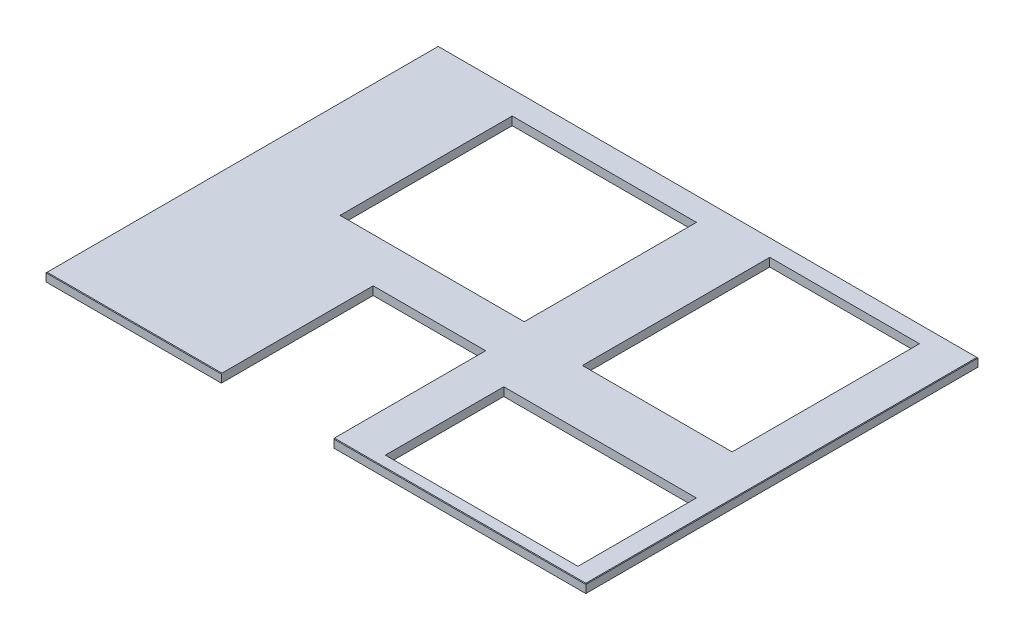
from build123d import *

# Parameters (mm, degrees)
SKETCH1_W           = 2438.4
SKETCH1_H           = 1771.65
BOSS_EXTRUDE1_DEPTH = 38.1
CHAMFER1_SIZE       = 2.54
SKETCH2_W           = 869.95
SKETCH2_H           = 534.9875
CUT_EXTRUDE1_DEPTH  = 39.1
SKETCH3_W           = 508
SKETCH3_H           = 685.8
CUT_EXTRUDE2_DEPTH  = 39.1
SKETCH4_W           = 676.20134
SKETCH4_H           = 846.33308
CUT_EXTRUDE3_DEPTH  = 39.1
SKETCH5_W           = 832.171110348
SKETCH5_H           = 777.705149966
CUT_EXTRUDE4_DEPTH  = 39.1


with BuildPart() as part:
    # Sketch1 → Boss-Extrude1 (new body)
    with BuildSketch(Plane(origin=(0, 0, 0), x_dir=(1, 0, 0), z_dir=(0, 1, 0))):
        with Locations((1219.2, 885.825)):
            Rectangle(SKETCH1_W, SKETCH1_H)
    extrude(amount=-BOSS_EXTRUDE1_DEPTH)

    # Chamfer1
    chamfer1_edges = [part.edges().sort_by_distance(p)[0] for p in [
        (0, 0, -885.825),
        (1219.2, 0, -1771.65),
        (2438.4, 0, -885.825),
        (1219.2, 0, 0),
    ]]
    chamfer(chamfer1_edges, length=CHAMFER1_SIZE)

    # Sketch2 → Cut-Extrude1 (cut, through all)
    with BuildSketch(Plane(origin=(0, 0, 0), x_dir=(1, 0, 0), z_dir=(0, 1, 0))):
        with Locations((1917.065, 318.29375)):
            Rectangle(SKETCH2_W, SKETCH2_H)
    extrude(amount=-CUT_EXTRUDE1_DEPTH, mode=Mode.SUBTRACT)

    # Sketch3 → Cut-Extrude2 (cut, through all)
    with BuildSketch(Plane(origin=(0, 0, 0), x_dir=(1, 0, 0), z_dir=(0, 1, 0))):
        with Locations((1046.1625, 342.9)):
            Rectangle(SKETCH3_W, SKETCH3_H)
    extrude(amount=-CUT_EXTRUDE2_DEPTH, mode=Mode.SUBTRACT)

    # Sketch4 → Cut-Extrude3 (cut, through all)
    with BuildSketch(Plane(origin=(0, 0, 0), x_dir=(1, 0, 0), z_dir=(0, 1, 0))):
        with Locations((1914.52627, 1269.74346)):
            Rectangle(SKETCH4_W, SKETCH4_H)
    extrude(amount=-CUT_EXTRUDE3_DEPTH, mode=Mode.SUBTRACT)

    # Sketch5 → Cut-Extrude4 (cut, through all)
    with BuildSketch(Plane(origin=(0, 0, 0), x_dir=(1, 0, 0), z_dir=(0, 1, 0))):
        with Locations((857.885146865, 1275.210240055)):
            Rectangle(SKETCH5_W, SKETCH5_H)
    extrude(amount=-CUT_EXTRUDE4_DEPTH, mode=Mode.SUBTRACT)


solid = part.part
